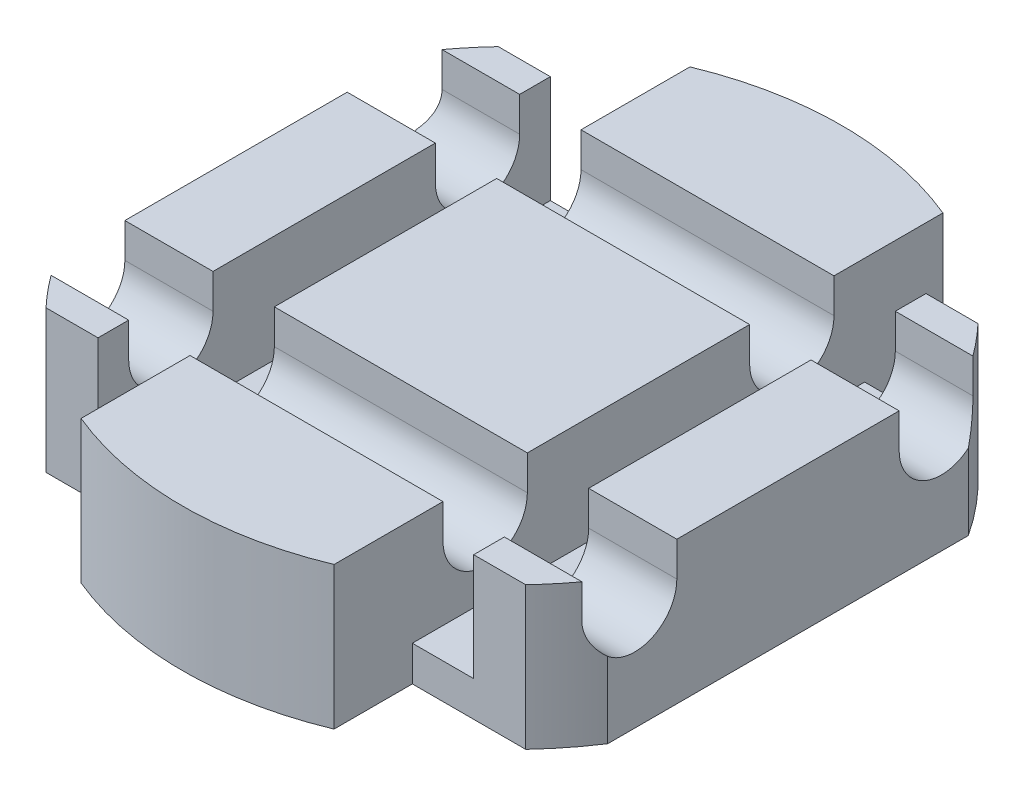
from build123d import *

# Parameters (mm, degrees)
Y_KSEKLIK_EKSTR_ZYON1_DEPTH = 9.3
KES_EKSTR_ZYON1_DEPTH       = 10.3
KES_EKSTR_ZYON2_DEPTH       = 37
IZIM4_W                     = 4
IZIM4_H                     = 7
KES_EKSTR_ZYON3_DEPTH       = 25


with BuildPart() as part:
    # Çizim1 → Yükseklik-Ekstrüzyon1 (new body)
    with BuildSketch(Plane(origin=(0, 0, 0), x_dir=(1, 0, 0), z_dir=(0, 1, 0))):
        with BuildLine():
            Line((18, -11.757976016), (18, 11.757976016))
            ThreePointArc((18, 11.757976016), (0, 21.5), (-18, 11.757976016))
            Line((-18, 11.757976016), (-18, -11.757976016))
            ThreePointArc((-18, -11.757976016), (0, -21.5), (18, -11.757976016))
        make_face()
    extrude(amount=-Y_KSEKLIK_EKSTR_ZYON1_DEPTH)

    # Çizim2 → Kes-Ekstrüzyon1 (cut, through all)
    with BuildSketch(Plane(origin=(0, 0, 0), x_dir=(1, 0, 0), z_dir=(0, 1, 0))):
        with BuildLine():
            Line((8.25, -14.75), (15.642490211, -14.75))
            ThreePointArc((15.642490211, -14.75), (12.215804254, -17.692487853), (8.25, -19.854155736))
            Line((8.25, -19.854155736), (8.25, -14.75))
        make_face()
        with BuildLine():
            Line((-8.25, -19.854155736), (-8.25, -14.75))
            Line((-8.25, -14.75), (-15.642490211, -14.75))
            ThreePointArc((-15.642490211, -14.75), (-12.215804254, -17.692487853), (-8.25, -19.854155736))
        make_face()
        with BuildLine():
            Line((8.25, 14.75), (15.642490211, 14.75))
            ThreePointArc((15.642490211, 14.75), (12.215804254, 17.692487853), (8.25, 19.854155736))
            Line((8.25, 19.854155736), (8.25, 14.75))
        make_face()
        with BuildLine():
            Line((-15.642490211, 14.75), (-8.25, 14.75))
            Line((-8.25, 14.75), (-8.25, 19.854155736))
            ThreePointArc((-8.25, 19.854155736), (-12.215804254, 17.692487853), (-15.642490211, 14.75))
        make_face()
    extrude(amount=-KES_EKSTR_ZYON1_DEPTH, mode=Mode.SUBTRACT)

    # Çizim3 → Kes-Ekstrüzyon2 (cut, through all)
    with BuildSketch(Plane(origin=(18, 0, 0), x_dir=(0, 0, -1), z_dir=(1, 0, 0))):
        with BuildLine():
            Line((-7.25, -2.25), (-7.25, 1))
            Line((-7.25, 1), (-12.75, 1))
            Line((-12.75, 1), (-12.75, -2.25))
            ThreePointArc((-12.75, -2.25), (-10, -5), (-7.25, -2.25))
        make_face()
        with BuildLine():
            Line((12.75, -2.25), (12.75, 1))
            Line((12.75, 1), (7.25, 1))
            Line((7.25, 1), (7.25, -2.25))
            ThreePointArc((7.25, -2.25), (10, -5), (12.75, -2.25))
        make_face()
    extrude(amount=-KES_EKSTR_ZYON2_DEPTH, mode=Mode.SUBTRACT)

    # Çizim4 → Kes-Ekstrüzyon3 (cut, symmetric)
    with BuildSketch(Plane.XY):
        with Locations((-10.25, -3.5)):
            Rectangle(IZIM4_W, IZIM4_H)
        with Locations((10.25, -3.5)):
            Rectangle(IZIM4_W, IZIM4_H)
    extrude(amount=KES_EKSTR_ZYON3_DEPTH, both=True, mode=Mode.SUBTRACT)


solid = part.part
